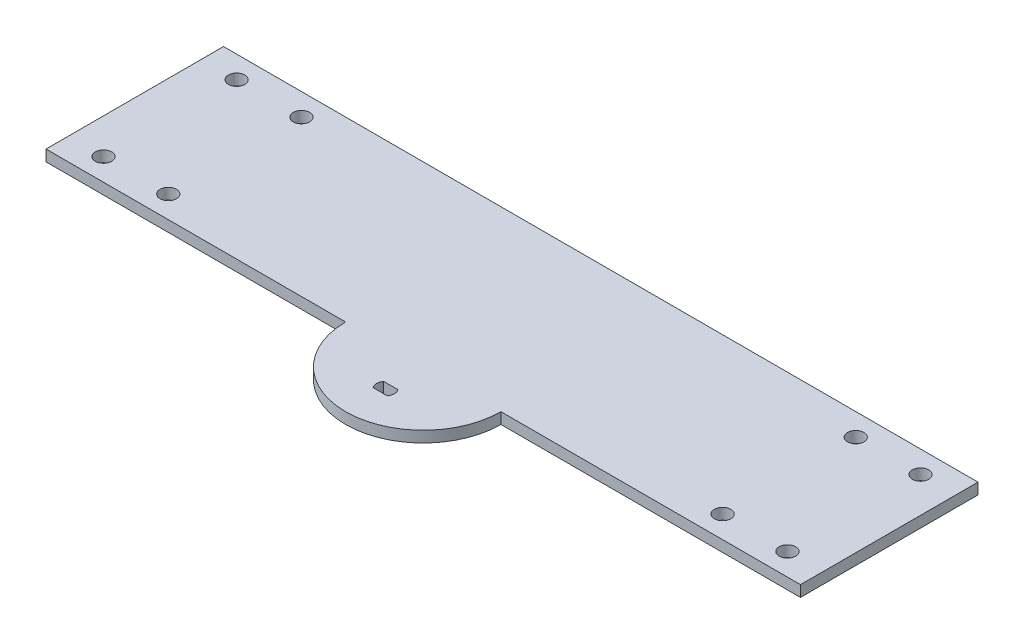
from build123d import *

# Parameters (mm, degrees)
BOSS_EXTRUDE1_DEPTH = 3.175
SKETCH2_R           = 2.3495
CUT_EXTRUDE1_DEPTH  = 4.175


with BuildPart() as part:
    # Sketch1 → Boss-Extrude1 (new body)
    with BuildSketch(Plane(origin=(0, 0, 0), x_dir=(1, 0, 0), z_dir=(0, 1, 0))):
        with BuildLine():
            Line((-107.95, 61.595), (107.95, 61.595))
            Line((107.95, 61.595), (107.95, 10.795))
            Line((107.95, 10.795), (22.225, 10.795))
            ThreePointArc((22.225, 10.795), (0, -11.43), (-22.225, 10.795))
            Line((-22.225, 10.795), (-107.95, 10.795))
            Line((-107.95, 10.795), (-107.95, 61.595))
        make_face()
        with BuildLine():
            Line((-2.032, 1.524), (2.032, 1.524))
            ThreePointArc((2.032, 1.524), (2.54, 0), (2.032, -1.524))
            Line((2.032, -1.524), (-2.032, -1.524))
            ThreePointArc((-2.032, -1.524), (-2.54, 0), (-2.032, 1.524))
        make_face(mode=Mode.SUBTRACT)
    extrude(amount=BOSS_EXTRUDE1_DEPTH)

    # Sketch2 → Cut-Extrude1 (cut, through all)
    with BuildSketch(Plane(origin=(0, 3.175, 0), x_dir=(1, 0, 0), z_dir=(0, 1, 0))):
        with Locations((-97.8535, 55.245)):
            Circle(SKETCH2_R)
        with Locations((-97.8535, 17.145)):
            Circle(SKETCH2_R)
        with Locations((-79.3115, 17.145)):
            Circle(SKETCH2_R)
        with Locations((-79.3115, 55.245)):
            Circle(SKETCH2_R)
        with Locations((79.3115, 55.245)):
            Circle(SKETCH2_R)
        with Locations((79.3115, 17.145)):
            Circle(SKETCH2_R)
        with Locations((97.8535, 17.145)):
            Circle(SKETCH2_R)
        with Locations((97.8535, 55.245)):
            Circle(SKETCH2_R)
    extrude(amount=-CUT_EXTRUDE1_DEPTH, mode=Mode.SUBTRACT)


solid = part.part
